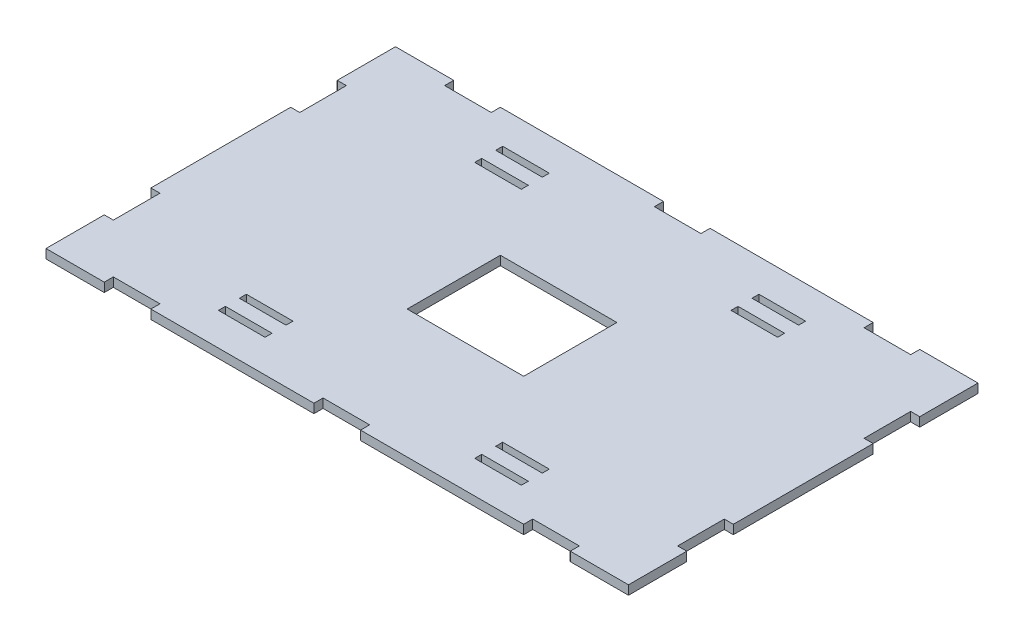
from build123d import *

# Parameters (mm, degrees)
SKETCH1_W           = 20
SKETCH1_H           = 3
SKETCH1_W_2         = 50
SKETCH1_H_2         = 40
BOSS_EXTRUDE1_DEPTH = 3.9


with BuildPart() as part:
    # Sketch1 → Boss-Extrude1 (new body)
    with BuildSketch(Plane(origin=(0, 0, 0), x_dir=(1, 0, 0), z_dir=(0, 1, 0))):
        Polygon((-125, 75), (-100, 75), (-100, 71.1), (-80, 71.1), (-80, 75), (-10, 75), (-10, 71.1), (10, 71.1), (10, 75), (80, 75), (80, 71.1), (100, 71.1), (100, 75), (125, 75), (125, 50), (121.1, 50), (121.1, 30), (125, 30), (125, -30), (121.1, -30), (121.1, -50), (125, -50), (125, -75), (100, -75), (100, -71.1), (80, -71.1), (80, -75), (10, -75), (10, -71.1), (-10, -71.1), (-10, -75), (-80, -75), (-80, -71.1), (-100, -71.1), (-100, -75), (-125, -75), (-125, -50), (-121.1, -50), (-121.1, -30), (-125, -30), (-125, 30), (-121.1, 30), (-121.1, 50), (-125, 50), align=None)
        with Locations((-55, -50.5)):
            Rectangle(SKETCH1_W, SKETCH1_H, mode=Mode.SUBTRACT)
        with Locations((-55, -59.5)):
            Rectangle(SKETCH1_W, SKETCH1_H, mode=Mode.SUBTRACT)
        Rectangle(SKETCH1_W_2, SKETCH1_H_2, mode=Mode.SUBTRACT)
        with Locations((55, -59.5)):
            Rectangle(SKETCH1_W, SKETCH1_H, mode=Mode.SUBTRACT)
        with Locations((55, -50.5)):
            Rectangle(SKETCH1_W, SKETCH1_H, mode=Mode.SUBTRACT)
        with Locations((55, 50.5)):
            Rectangle(SKETCH1_W, SKETCH1_H, mode=Mode.SUBTRACT)
        with Locations((55, 59.5)):
            Rectangle(SKETCH1_W, SKETCH1_H, mode=Mode.SUBTRACT)
        with Locations((-55, 59.5)):
            Rectangle(SKETCH1_W, SKETCH1_H, mode=Mode.SUBTRACT)
        with Locations((-55, 50.5)):
            Rectangle(SKETCH1_W, SKETCH1_H, mode=Mode.SUBTRACT)
    extrude(amount=BOSS_EXTRUDE1_DEPTH)


solid = part.part
